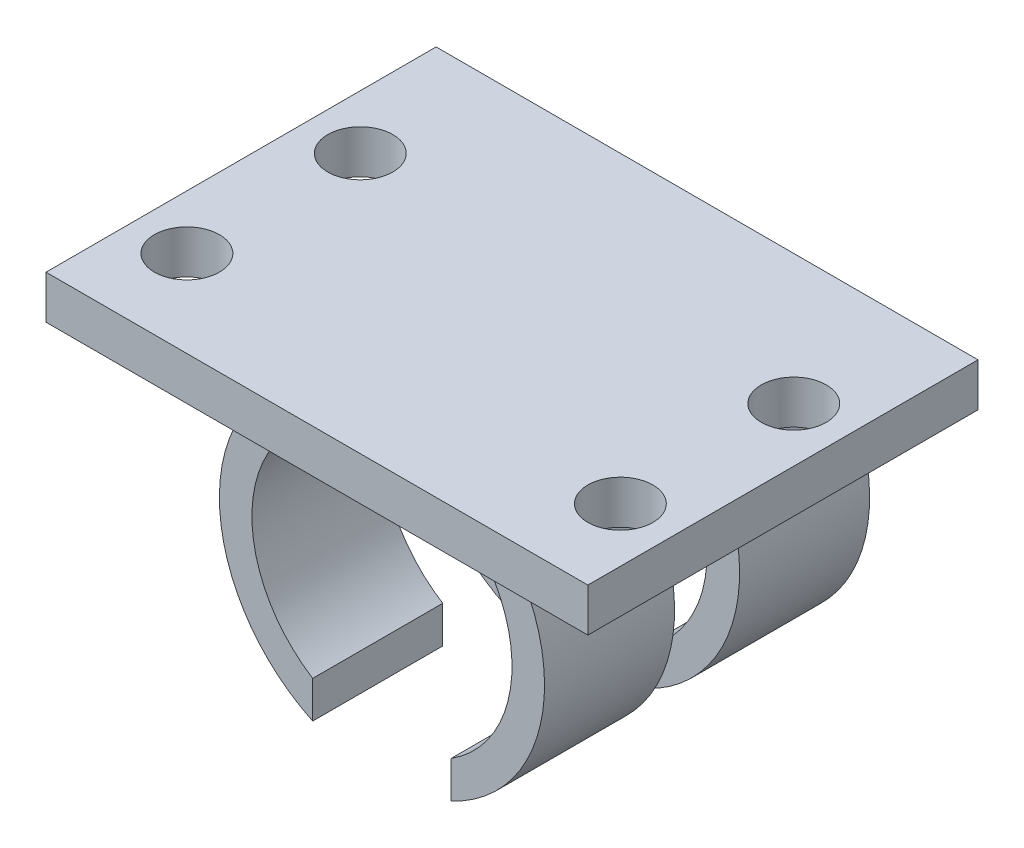
from build123d import *

# Parameters (mm, degrees)
EXTRUDE_1_DEPTH     = 15
CUT_EXTRUDE_1_DEPTH = 7.5
EXTRUDE_3_DEPTH     = 18
SKETCH_3_R          = 1.5
CUT_EXTRUDE_2_DEPTH = 10


with BuildPart() as part:
    # 草图1 → 凸台-拉伸1 (new body)
    with BuildSketch(Plane.XY):
        with BuildLine():
            ThreePointArc((3.195328917, -6.785268831), (7.461194526, -0.761955539), (4.500921435, 5.999308813))
            Line((4.500921435, 5.999308813), (-4.500433628, 5.999674755))
            ThreePointArc((-4.500433628, 5.999674755), (-7.461256455, -0.761348873), (-3.195880618, -6.785008996))
            Line((-3.195880618, -6.785008996), (-3.195880618, -5.078025903))
            ThreePointArc((-3.195880618, -5.078025903), (-5.999570878, -0.071758494), (-3.316421512, 5.000134834))
            Line((-3.316421512, 5.000134834), (3.316828063, 4.999865158))
            ThreePointArc((3.316828063, 4.999865158), (5.999565023, -0.07224632), (3.195467712, -5.078285744))
            Line((3.195467712, -5.078285744), (3.195328917, -6.785268831))
        make_face()
    extrude(amount=EXTRUDE_1_DEPTH)

    # 草图2 → 切除-拉伸1 (cut, symmetric)
    with BuildSketch(Plane(origin=(0, 0, 0), x_dir=(0, 0, -1), z_dir=(1, 0, 0))):
        Polygon((-7.5, -6.785268831), (-6, -6.785268831), (-6, 3.214731169), (-9, 3.214731169), (-9, -6.785268831), align=None)
    extrude(amount=CUT_EXTRUDE_1_DEPTH, both=True, mode=Mode.SUBTRACT)

    # 草图1<4> → 凸台-拉伸3 (add)
    with BuildSketch(Plane.XY):
        Polygon((12.500487826, 5.998983598), (12.500650474, 7.999329111), (-12.500650425, 8.000345629), (-12.500650425, 5.999999996), (-4.500433628, 5.999674755), (4.500921435, 5.999308813), align=None)
    extrude(amount=EXTRUDE_3_DEPTH)

    # 草图3 → 切除-拉伸2 (cut)
    with BuildSketch(Plane(origin=(0.000325262, 7.999837357, 0), x_dir=(0.9999999991734381, -4.0658628313075474e-05, 0), z_dir=(4.0658628313075474e-05, 0.9999999991734381, 0))):
        with Locations((-10.000975697, -6)):
            Circle(SKETCH_3_R)
        with Locations((-10.000975697, -14)):
            Circle(SKETCH_3_R)
        with Locations((10.000867281, -6.000271056)):
            Circle(SKETCH_3_R)
        with Locations((10.000650456, -14.000271053)):
            Circle(SKETCH_3_R)
    extrude(amount=-CUT_EXTRUDE_2_DEPTH, mode=Mode.SUBTRACT)


solid = part.part
